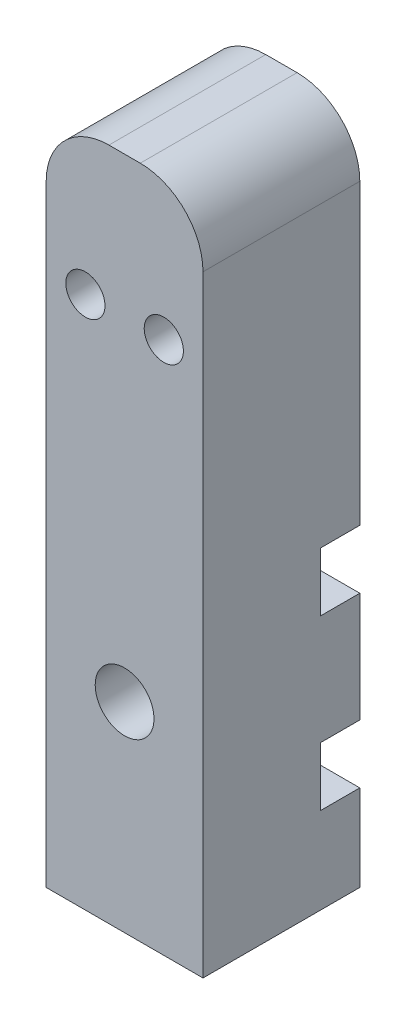
from build123d import *

# Parameters (mm, degrees)
SKETCH1_W           = 25.4
SKETCH1_H           = 109.22
BOSS_EXTRUDE1_DEPTH = 25.4
FILLET1_R           = 10.16
SKETCH2_R           = 3.175
CUT_EXTRUDE1_DEPTH  = 17.78
SKETCH3_R           = 4.7625
SKETCH3_R_2         = 3.175
CUT_EXTRUDE2_DEPTH  = 62.552433746
SKETCH3_3_R         = 4.7625
CUT_EXTRUDE3_DEPTH  = 16.51
SKETCH4_W           = 25.4
SKETCH4_H           = 9.525
CUT_EXTRUDE4_DEPTH  = 6.35


with BuildPart() as part:
    # Sketch1 → Boss-Extrude1 (new body)
    with BuildSketch(Plane.XY):
        Rectangle(SKETCH1_W, SKETCH1_H)
    extrude(amount=-BOSS_EXTRUDE1_DEPTH)

    # Fillet1
    fillet1_edges = [part.edges().sort_by_distance(p)[0] for p in [
        (12.7, 54.61, -12.7),
        (-12.7, 54.61, -12.7),
    ]]
    fillet(fillet1_edges, radius=FILLET1_R)

    # Sketch2 → Cut-Extrude1 (cut)
    with BuildSketch(Plane.XZ.offset(54.61)):
        with Locations((0, -12.7)):
            Circle(SKETCH2_R)
    extrude(amount=-CUT_EXTRUDE1_DEPTH, mode=Mode.SUBTRACT)

    # Sketch3 → Cut-Extrude2 (cut, through all)
    with BuildSketch(Plane(origin=(0, 0, -25.4), x_dir=(-1, 0, 0), z_dir=(0, 0, -1))):
        with Locations((0, -22.225)):
            Circle(SKETCH3_R)
        with Locations((6.35, 31.75)):
            Circle(SKETCH3_R_2)
        with Locations((-6.35, 31.75)):
            Circle(SKETCH3_R_2)
    extrude(amount=-CUT_EXTRUDE2_DEPTH, mode=Mode.SUBTRACT)

    # Sketch3_3 → Cut-Extrude3 (cut)
    with BuildSketch(Plane(origin=(0, 0, -25.4), x_dir=(-1, 0, 0), z_dir=(0, 0, -1))):
        with Locations((0, 46.736)):
            Circle(SKETCH3_3_R)
    extrude(amount=-CUT_EXTRUDE3_DEPTH, mode=Mode.SUBTRACT)

    # Sketch4 → Cut-Extrude4 (cut)
    with BuildSketch(Plane(origin=(0, 0, -25.4), x_dir=(-1, 0, 0), z_dir=(0, 0, -1))):
        with Locations((0, -8.5725)):
            Rectangle(SKETCH4_W, SKETCH4_H)
        with Locations((0, -35.8775)):
            Rectangle(SKETCH4_W, SKETCH4_H)
    extrude(amount=-CUT_EXTRUDE4_DEPTH, mode=Mode.SUBTRACT)


solid = part.part
